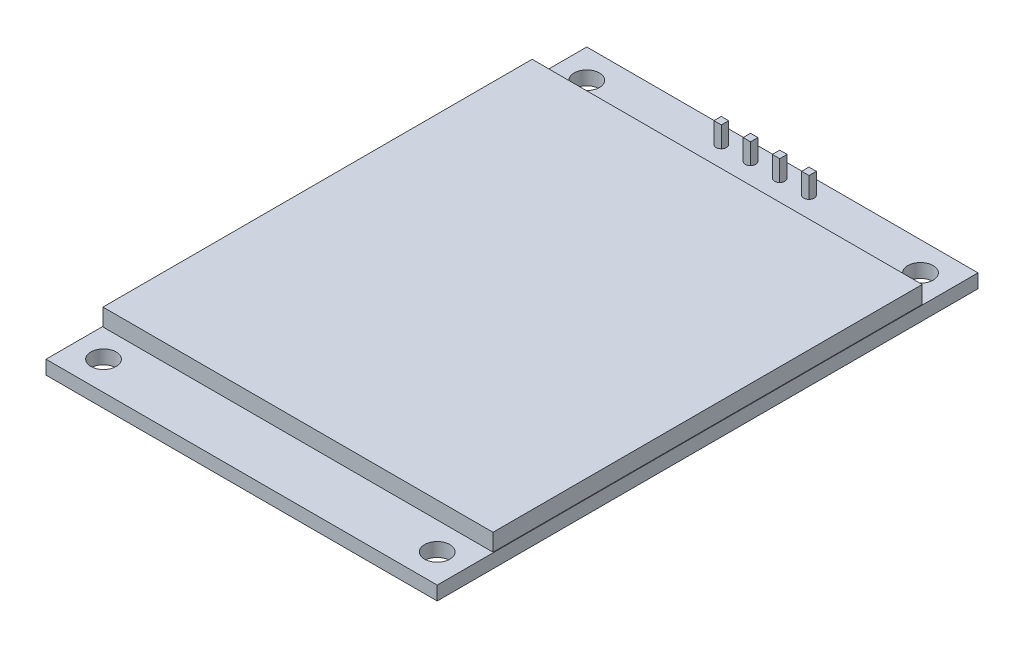
from build123d import *

# Parameters (mm, degrees)
SKETCH1_W             = 34
SKETCH1_H             = 47
BOSS_EXTRUDE1_DEPTH   = 0.6
SKETCH2_R             = 1.1
CUT_EXTRUDE1_DEPTH    = 2.2
SKETCH3_R             = 0.45
CUT_EXTRUDE2_DEPTH    = 2.2
SKETCH4_W             = 10.16
SKETCH4_H             = 2.54
SKETCH4_R             = 0.45
BOSS_EXTRUDE2_DEPTH   = 2.54
BOSS_EXTRUDE3_START   = 1.8
SKETCH5_W             = 0.64
SKETCH5_H             = 0.64
BOSS_EXTRUDE3_DEPTH   = 11.3
BOSS_EXTRUDE3_2_DEPTH = 11.3
BOSS_EXTRUDE3_3_DEPTH = 11.3
BOSS_EXTRUDE3_4_DEPTH = 11.3
SKETCH6_W             = 33.9
SKETCH6_H             = 37.3
BOSS_EXTRUDE4_DEPTH   = 1.5


with BuildPart() as part:
    # Sketch1 → Boss-Extrude1 (new body, symmetric)
    with BuildSketch(Plane(origin=(0, 0, 0), x_dir=(1, 0, 0), z_dir=(0, 1, 0))):
        Rectangle(SKETCH1_W, SKETCH1_H)
    extrude(amount=BOSS_EXTRUDE1_DEPTH, both=True)

    # Sketch2 → Cut-Extrude1 (cut, through all)
    with BuildSketch(Plane(origin=(0, 0.6, 0), x_dir=(1, 0, 0), z_dir=(0, 1, 0))):
        with Locations((-14.5, 21)):
            Circle(SKETCH2_R)
        with Locations((14.5, 21)):
            Circle(SKETCH2_R)
        with Locations((14.5, -21)):
            Circle(SKETCH2_R)
        with Locations((-14.5, -21)):
            Circle(SKETCH2_R)
    extrude(amount=-CUT_EXTRUDE1_DEPTH, mode=Mode.SUBTRACT)

    # Sketch3 → Cut-Extrude2 (cut, through all)
    with BuildSketch(Plane(origin=(0, 0.6, 0), x_dir=(1, 0, 0), z_dir=(0, 1, 0))):
        with Locations((-3.81, 22)):
            Circle(SKETCH3_R)
        with Locations((-1.27, 22)):
            Circle(SKETCH3_R)
        with Locations((1.27, 22)):
            Circle(SKETCH3_R)
        with Locations((3.81, 22)):
            Circle(SKETCH3_R)
    extrude(amount=-CUT_EXTRUDE2_DEPTH, mode=Mode.SUBTRACT)


with BuildPart() as body_2:
    # Sketch4 → Boss-Extrude2 (new body)
    with BuildSketch(Plane.XZ.offset(0.6)):
        with Locations((0, -22)):
            Rectangle(SKETCH4_W, SKETCH4_H)
        with Locations((3.81, -22)):
            Circle(SKETCH4_R, mode=Mode.SUBTRACT)
        with Locations((1.27, -22)):
            Circle(SKETCH4_R, mode=Mode.SUBTRACT)
        with Locations((-1.27, -22)):
            Circle(SKETCH4_R, mode=Mode.SUBTRACT)
        with Locations((-3.81, -22)):
            Circle(SKETCH4_R, mode=Mode.SUBTRACT)
    extrude(amount=BOSS_EXTRUDE2_DEPTH)


with BuildPart() as body_3:
    # Sketch5 → Boss-Extrude3 (new body)
    with BuildSketch(Plane(origin=(0, 0.6, 0), x_dir=(1, 0, 0), z_dir=(0, 1, 0)).offset(BOSS_EXTRUDE3_START)):
        with Locations((-1.27, 22)):
            Rectangle(SKETCH5_W, SKETCH5_H)
    extrude(amount=-BOSS_EXTRUDE3_DEPTH)


with BuildPart() as body_4:
    # Sketch5 → Boss-Extrude3 2 (new body)
    with BuildSketch(Plane(origin=(0, 0.6, 0), x_dir=(1, 0, 0), z_dir=(0, 1, 0)).offset(BOSS_EXTRUDE3_START)):
        with Locations((-3.81, 22)):
            Rectangle(SKETCH5_W, SKETCH5_H)
    extrude(amount=-BOSS_EXTRUDE3_2_DEPTH)


with BuildPart() as body_5:
    # Sketch5 → Boss-Extrude3 3 (new body)
    with BuildSketch(Plane(origin=(0, 0.6, 0), x_dir=(1, 0, 0), z_dir=(0, 1, 0)).offset(BOSS_EXTRUDE3_START)):
        with Locations((1.27, 22)):
            Rectangle(SKETCH5_W, SKETCH5_H)
    extrude(amount=-BOSS_EXTRUDE3_3_DEPTH)


with BuildPart() as body_6:
    # Sketch5 → Boss-Extrude3 4 (new body)
    with BuildSketch(Plane(origin=(0, 0.6, 0), x_dir=(1, 0, 0), z_dir=(0, 1, 0)).offset(BOSS_EXTRUDE3_START)):
        with Locations((3.81, 22)):
            Rectangle(SKETCH5_W, SKETCH5_H)
    extrude(amount=-BOSS_EXTRUDE3_4_DEPTH)


with BuildPart() as body_7:
    # Sketch6 → Boss-Extrude4 (new body)
    with BuildSketch(Plane(origin=(0, 0.6, 0), x_dir=(1, 0, 0), z_dir=(0, 1, 0))):
        with Locations((0, 0.05)):
            Rectangle(SKETCH6_W, SKETCH6_H)
    extrude(amount=BOSS_EXTRUDE4_DEPTH)


solid = Compound([part.part, body_2.part, body_3.part, body_4.part, body_5.part, body_6.part, body_7.part])
